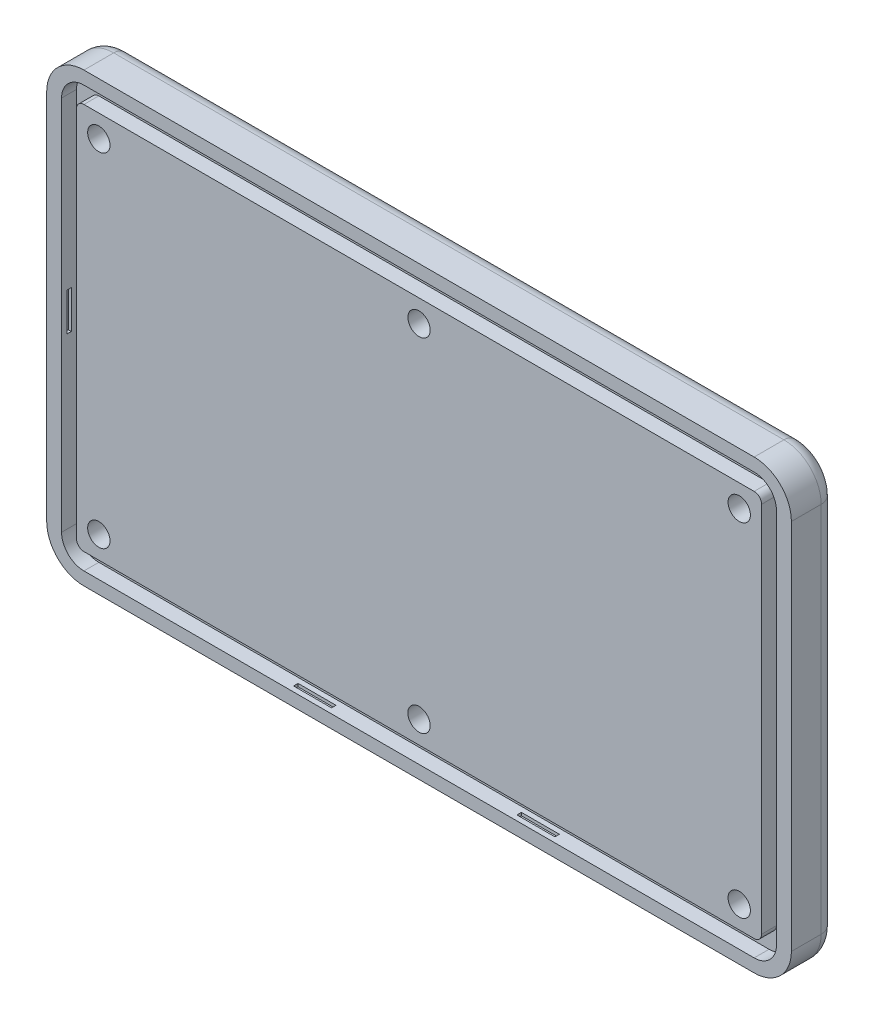
from build123d import *

# Parameters (mm, degrees)
SKETCH_1_W          = 100
SKETCH_1_H          = 60
EXTRUDE_1_DEPTH     = 6
FILLET_1_R          = 5
FILLET_2_R          = 2
CUT_EXTRUDE_1_DEPTH = 2
SKETCH_4_W          = 5.1
SKETCH_4_H          = 0.6
CUT_EXTRUDE_2_DEPTH = 0.4
SKETCH_5_W          = 5.1
SKETCH_5_H          = 0.6
CUT_EXTRUDE_3_DEPTH = 0.4
SKETCH_6_W          = 0.6
SKETCH_6_H          = 5.1
CUT_EXTRUDE_4_DEPTH = 0.4
SKETCH_7_W          = 0.6
SKETCH_7_H          = 5.1
CUT_EXTRUDE_5_DEPTH = 0.4
EXTRUDE_2_DEPTH     = 2
CUT_EXTRUDE_6_REACH = 8
SKETCH_9_R          = 1.5
SKETCH_10_R         = 3.05
CUT_EXTRUDE_7_DEPTH = 1.1
FILLET_3_R          = 0.5


with BuildPart() as part:
    # 草图1 → 凸台-拉伸1 (new body)
    with BuildSketch(Plane.XY):
        Rectangle(SKETCH_1_W, SKETCH_1_H)
    extrude(amount=EXTRUDE_1_DEPTH)

    # 圆角1
    fillet_1_edges = [part.edges().sort_by_distance(p)[0] for p in [
        (-50, 30, 3),
        (50, 30, 3),
        (50, -30, 3),
        (-50, -30, 3),
    ]]
    fillet(fillet_1_edges, radius=FILLET_1_R)

    # 圆角2
    fillet_2_edges = [part.edges().sort_by_distance(p)[0] for p in [
        (0, -30, 0),
        (-50, 0, 0),
        (0, 30, 0),
        (50, 0, 0),
        (-48.535533906, 28.535533906, 0),
        (48.535533906, 28.535533906, 0),
        (48.535533906, -28.535533906, 0),
        (-48.535533906, -28.535533906, 0),
    ]]
    fillet(fillet_2_edges, radius=FILLET_2_R)

    # 草图2 → 切除-拉伸1 (cut)
    with BuildSketch(Plane.XY.offset(6)):
        with BuildLine():
            Line((-45, 28.25), (45, 28.25))
            ThreePointArc((45, 28.25), (47.121320344, 27.371320344), (48, 25.25))
            Line((48, 25.25), (48, -25.25))
            ThreePointArc((48, -25.25), (47.121320344, -27.371320344), (45, -28.25))
            Line((45, -28.25), (-45, -28.25))
            ThreePointArc((-45, -28.25), (-47.121320344, -27.371320344), (-48, -25.25))
            Line((-48, -25.25), (-48, 25.25))
            ThreePointArc((-48, 25.25), (-47.121320344, 27.371320344), (-45, 28.25))
        make_face()
    extrude(amount=-CUT_EXTRUDE_1_DEPTH, mode=Mode.SUBTRACT)

    # 草图4 → 切除-拉伸2 (cut)
    with BuildSketch(Plane(origin=(0, -28.25, 0), x_dir=(1, 0, 0), z_dir=(0, 1, 0))):
        with Locations((15, -5)):
            Rectangle(SKETCH_4_W, SKETCH_4_H)
        with Locations((-15, -5)):
            Rectangle(SKETCH_4_W, SKETCH_4_H)
    extrude(amount=-CUT_EXTRUDE_2_DEPTH, mode=Mode.SUBTRACT)

    # 草图5 → 切除-拉伸3 (cut)
    with BuildSketch(Plane.XZ.offset(-28.25)):
        with Locations((-15, 5)):
            Rectangle(SKETCH_5_W, SKETCH_5_H)
        with Locations((15, 5)):
            Rectangle(SKETCH_5_W, SKETCH_5_H)
    extrude(amount=-CUT_EXTRUDE_3_DEPTH, mode=Mode.SUBTRACT)

    # 草图6 → 切除-拉伸4 (cut)
    with BuildSketch(Plane(origin=(-48, 0, 0), x_dir=(0, 0, -1), z_dir=(1, 0, 0))):
        with Locations((-5, 0)):
            Rectangle(SKETCH_6_W, SKETCH_6_H)
    extrude(amount=-CUT_EXTRUDE_4_DEPTH, mode=Mode.SUBTRACT)

    # 草图7 → 切除-拉伸5 (cut)
    with BuildSketch(Plane.ZY.offset(-48)):
        with Locations((5, 0)):
            Rectangle(SKETCH_7_W, SKETCH_7_H)
    extrude(amount=-CUT_EXTRUDE_5_DEPTH, mode=Mode.SUBTRACT)

    # 草图8 → 凸台-拉伸2 (add)
    with BuildSketch(Plane.XY.offset(4)):
        with BuildLine():
            Line((45, -26), (-45, -26))
            ThreePointArc((-45, -26), (-45.707106781, -25.707106781), (-46, -25))
            Line((-46, -25), (-46, 25))
            ThreePointArc((-46, 25), (-45.707106781, 25.707106781), (-45, 26))
            Line((-45, 26), (45, 26))
            ThreePointArc((45, 26), (45.707106781, 25.707106781), (46, 25))
            Line((46, 25), (46, -25))
            ThreePointArc((46, -25), (45.707106781, -25.707106781), (45, -26))
        make_face()
    extrude(amount=EXTRUDE_2_DEPTH)

    # 草图9 → 切除-拉伸6 (cut, up to next)
    with BuildSketch(Plane.XY.offset(6), mode=Mode.PRIVATE) as cut_extrude_6_sk1:
        with Locations((43, 23)):
            Circle(SKETCH_9_R)
    cut_extrude_6_tool1 = extrude(cut_extrude_6_sk1.sketch, amount=-CUT_EXTRUDE_6_REACH, mode=Mode.PRIVATE) & part.part
    add(cut_extrude_6_tool1.solids().sort_by_distance((43, 23, 6))[0], mode=Mode.SUBTRACT)
    # 草图9 → 切除-拉伸6 (cut, up to next)
    with BuildSketch(Plane.XY.offset(6), mode=Mode.PRIVATE) as cut_extrude_6_sk2:
        with Locations((0, 23)):
            Circle(SKETCH_9_R)
    cut_extrude_6_tool2 = extrude(cut_extrude_6_sk2.sketch, amount=-CUT_EXTRUDE_6_REACH, mode=Mode.PRIVATE) & part.part
    add(cut_extrude_6_tool2.solids().sort_by_distance((0, 23, 6))[0], mode=Mode.SUBTRACT)
    # 草图9 → 切除-拉伸6 (cut, up to next)
    with BuildSketch(Plane.XY.offset(6), mode=Mode.PRIVATE) as cut_extrude_6_sk3:
        with Locations((-43, 23)):
            Circle(SKETCH_9_R)
    cut_extrude_6_tool3 = extrude(cut_extrude_6_sk3.sketch, amount=-CUT_EXTRUDE_6_REACH, mode=Mode.PRIVATE) & part.part
    add(cut_extrude_6_tool3.solids().sort_by_distance((-43, 23, 6))[0], mode=Mode.SUBTRACT)
    # 草图9 → 切除-拉伸6 (cut, up to next)
    with BuildSketch(Plane.XY.offset(6), mode=Mode.PRIVATE) as cut_extrude_6_sk4:
        with Locations((-43, -23)):
            Circle(SKETCH_9_R)
    cut_extrude_6_tool4 = extrude(cut_extrude_6_sk4.sketch, amount=-CUT_EXTRUDE_6_REACH, mode=Mode.PRIVATE) & part.part
    add(cut_extrude_6_tool4.solids().sort_by_distance((-43, -23, 6))[0], mode=Mode.SUBTRACT)
    # 草图9 → 切除-拉伸6 (cut, up to next)
    with BuildSketch(Plane.XY.offset(6), mode=Mode.PRIVATE) as cut_extrude_6_sk5:
        with Locations((0, -23)):
            Circle(SKETCH_9_R)
    cut_extrude_6_tool5 = extrude(cut_extrude_6_sk5.sketch, amount=-CUT_EXTRUDE_6_REACH, mode=Mode.PRIVATE) & part.part
    add(cut_extrude_6_tool5.solids().sort_by_distance((0, -23, 6))[0], mode=Mode.SUBTRACT)
    # 草图9 → 切除-拉伸6 (cut, up to next)
    with BuildSketch(Plane.XY.offset(6), mode=Mode.PRIVATE) as cut_extrude_6_sk6:
        with Locations((43, -23)):
            Circle(SKETCH_9_R)
    cut_extrude_6_tool6 = extrude(cut_extrude_6_sk6.sketch, amount=-CUT_EXTRUDE_6_REACH, mode=Mode.PRIVATE) & part.part
    add(cut_extrude_6_tool6.solids().sort_by_distance((43, -23, 6))[0], mode=Mode.SUBTRACT)

    # 草图10 → 切除-拉伸7 (cut)
    with BuildSketch(Plane(origin=(0, 0, 0), x_dir=(-1, 0, 0), z_dir=(0, 0, -1))):
        with Locations((43, 23)):
            Circle(SKETCH_10_R)
        with Locations((0, 23)):
            Circle(SKETCH_10_R)
        with Locations((-43, 23)):
            Circle(SKETCH_10_R)
        with Locations((-43, -23)):
            Circle(SKETCH_10_R)
        with Locations((0, -23)):
            Circle(SKETCH_10_R)
        with Locations((43, -23)):
            Circle(SKETCH_10_R)
    extrude(amount=-CUT_EXTRUDE_7_DEPTH, mode=Mode.SUBTRACT)

    # 圆角3
    fillet_3_edges = [part.edges().sort_by_distance(p)[0] for p in [
        (-39.95, -23, 0),
        (3.05, -23, 0),
        (46.05, -23, 0),
        (46.05, 23, 0),
        (3.05, 23, 0),
        (-39.95, 23, 0),
    ]]
    fillet(fillet_3_edges, radius=FILLET_3_R)


solid = part.part
